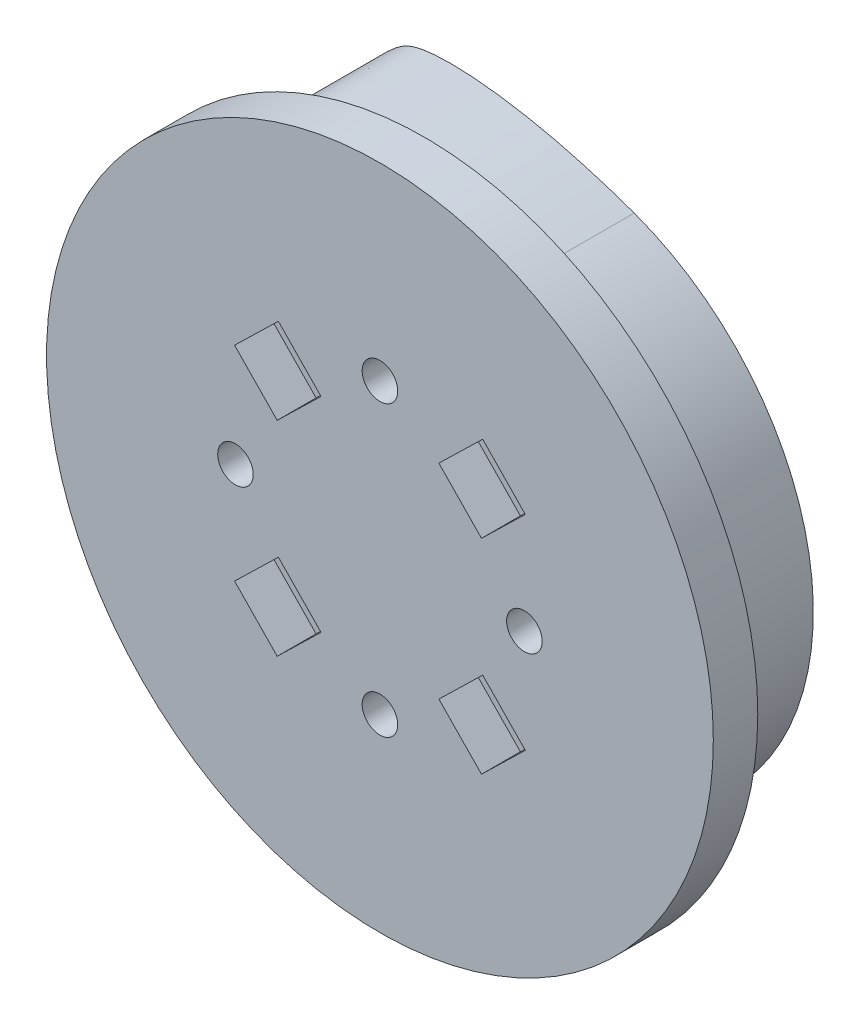
from build123d import *

# Parameters (mm, degrees)
SKETCH1_R           = 21
SKETCH1_R_2         = 2.85
SKETCH1_R_3         = 1.6
BOSS_EXTRUDE1_DEPTH = 10.5
SKETCH2_R           = 24.5
SKETCH2_R_2         = 21
BOSS_EXTRUDE3_DEPTH = 10.5
SKETCH4_R           = 30
SKETCH4_R_2         = 1.6
BOSS_EXTRUDE5_DEPTH = 4
SKETCH3_R           = 21
SKETCH3_R_2         = 1.6
BOSS_EXTRUDE4_DEPTH = 0.5
SKETCH6_W           = 5.5
SKETCH6_H           = 5.5
CUT_EXTRUDE2_DEPTH  = 3.5
SKETCH7_R           = 1.6
CUT_EXTRUDE3_DEPTH  = 46.000000133
SKETCH7_3_R         = 1.6
CUT_EXTRUDE4_DEPTH  = 3.5


with BuildPart() as part:
    # Sketch1 → Boss-Extrude1 (new body)
    with BuildSketch(Plane(origin=(0, 0, 0), x_dir=(0, 1, 0), z_dir=(0, 0, 1))):
        with Locations(Location((0, 0, 0), (0, 0, 90))):
            Circle(SKETCH1_R)
        with Locations((-13, 0)):
            Circle(SKETCH1_R_2, mode=Mode.SUBTRACT)
        with Locations((0, -13)):
            Circle(SKETCH1_R_2, mode=Mode.SUBTRACT)
        with Locations((13, 0)):
            Circle(SKETCH1_R_2, mode=Mode.SUBTRACT)
        with Locations((0, 13)):
            Circle(SKETCH1_R_2, mode=Mode.SUBTRACT)
        with Locations((-13, 0)):
            Circle(SKETCH1_R_2)
        with Locations(Location((-13, 0, 0), (0, 0, 90))):
            Circle(SKETCH1_R_3, mode=Mode.SUBTRACT)
        with Locations((0, 13)):
            Circle(SKETCH1_R_2)
        with Locations(Location((0, 13, 0), (0, 0, 90))):
            Circle(SKETCH1_R_3, mode=Mode.SUBTRACT)
        with Locations((13, 0)):
            Circle(SKETCH1_R_2)
        with Locations(Location((13, 0, 0), (0, 0, 90))):
            Circle(SKETCH1_R_3, mode=Mode.SUBTRACT)
        with Locations((0, -13)):
            Circle(SKETCH1_R_2)
        with Locations(Location((0, -13, 0), (0, 0, 90))):
            Circle(SKETCH1_R_3, mode=Mode.SUBTRACT)
    extrude(amount=BOSS_EXTRUDE1_DEPTH)

    # Sketch2 → Boss-Extrude3 (add)
    with BuildSketch(Plane(origin=(0, 0, 0), x_dir=(1, 0, 0), z_dir=(0, 0, -1))):
        Circle(SKETCH2_R)
        Circle(SKETCH2_R_2, mode=Mode.SUBTRACT)
        with BuildLine():
            ThreePointArc((8.379493511, -23.022469209), (-10.354147413, -22.204540782), (-23.022469209, -8.379493511))
            add(Edge.make_bspline(
                [(-23.022469209, -8.379493511), (-19.944287919, -16.836727099), (-14.723681196, -24.624750138), (-9.399453165, -27.107478442), (-0.077740076, -26.100650499), (8.379493511, -23.022469209)],
                knots=[0, 0, 0, 0, 0.45, 0.55, 1, 1, 1, 1], degree=3))
        make_face()
    extrude(amount=-BOSS_EXTRUDE3_DEPTH)

    # Sketch4 → Boss-Extrude5 (add)
    with BuildSketch(Plane.XY.offset(10.5)):
        Circle(SKETCH4_R)
        with Locations(Location((-13, 0, 0), (0, 0, 180))):
            Circle(SKETCH4_R_2, mode=Mode.SUBTRACT)
        with Locations(Location((0, 13, 0), (0, 0, 180))):
            Circle(SKETCH4_R_2, mode=Mode.SUBTRACT)
        with Locations(Location((13, 0, 0), (0, 0, 180))):
            Circle(SKETCH4_R_2, mode=Mode.SUBTRACT)
        with Locations(Location((0, -13, 0), (0, 0, 180))):
            Circle(SKETCH4_R_2, mode=Mode.SUBTRACT)
    extrude(amount=BOSS_EXTRUDE5_DEPTH)

    # Sketch3 → Boss-Extrude4 (add)
    with BuildSketch(Plane(origin=(0, 0, 0), x_dir=(1, 0, 0), z_dir=(0, 0, -1))):
        with Locations(Location((0, 0, 0), (0, 0, 180))):
            Circle(SKETCH3_R)
        with Locations(Location((-13, 0, 0), (0, 0, 180))):
            Circle(SKETCH3_R_2, mode=Mode.SUBTRACT)
        with Locations(Location((0, 13, 0), (0, 0, 180))):
            Circle(SKETCH3_R_2, mode=Mode.SUBTRACT)
        with Locations(Location((13, 0, 0), (0, 0, 180))):
            Circle(SKETCH3_R_2, mode=Mode.SUBTRACT)
        with Locations(Location((0, -13, 0), (0, 0, 180))):
            Circle(SKETCH3_R_2, mode=Mode.SUBTRACT)
    extrude(amount=BOSS_EXTRUDE4_DEPTH)

    # Sketch6 → Cut-Extrude2 (cut)
    with BuildSketch(Plane(origin=(0, 0, -0.5), x_dir=(1, 0, 0), z_dir=(0, 0, -1))):
        with Locations((13, 0)):
            Rectangle(SKETCH6_W, SKETCH6_H)
        with Locations((0, 13)):
            Rectangle(SKETCH6_W, SKETCH6_H)
        with Locations((0, -13)):
            Rectangle(SKETCH6_W, SKETCH6_H)
        with Locations((-13, 0)):
            Rectangle(SKETCH6_W, SKETCH6_H)
    extrude(amount=-CUT_EXTRUDE2_DEPTH, mode=Mode.SUBTRACT)

    # Sketch7 → Cut-Extrude3 (cut, through all)
    with BuildSketch(Plane.XY.offset(14.5)):
        with Locations((9.192388155, 9.192388155)):
            Circle(SKETCH7_R)
        with Locations((9.192388155, -9.192388155)):
            Circle(SKETCH7_R)
        with Locations((-9.192388155, -9.192388155)):
            Circle(SKETCH7_R)
        with Locations((-9.192388155, 9.192388155)):
            Circle(SKETCH7_R)
    extrude(amount=-CUT_EXTRUDE3_DEPTH, mode=Mode.SUBTRACT)

    # Sketch7_3 → Cut-Extrude4 (cut)
    with BuildSketch(Plane.XY.offset(14.5)):
        Polygon((9.245595054, 13.080678059), (5.304110209, 9.246461763), (9.139181257, 5.304098252), (13.080666102, 9.138314547), align=None)
        with Locations((9.192388155, 9.192388155)):
            Circle(SKETCH7_3_R, mode=Mode.SUBTRACT)
        Polygon((9.138314547, -13.080666102), (5.304098252, -9.139181257), (9.246461763, -5.304110209), (13.080678059, -9.245595054), align=None)
        with Locations((9.192388155, -9.192388155)):
            Circle(SKETCH7_3_R, mode=Mode.SUBTRACT)
        Polygon((-13.080666102, -9.138314547), (-9.139181257, -5.304098252), (-5.304110209, -9.246461763), (-9.245595054, -13.080678059), align=None)
        with Locations((-9.192388155, -9.192388155)):
            Circle(SKETCH7_3_R, mode=Mode.SUBTRACT)
        Polygon((-9.138314547, 13.080666102), (-5.304098252, 9.139181257), (-9.246461763, 5.304110209), (-13.080678059, 9.245595054), align=None)
        with Locations((-9.192388155, 9.192388155)):
            Circle(SKETCH7_3_R, mode=Mode.SUBTRACT)
    extrude(amount=-CUT_EXTRUDE4_DEPTH, mode=Mode.SUBTRACT)


solid = part.part
